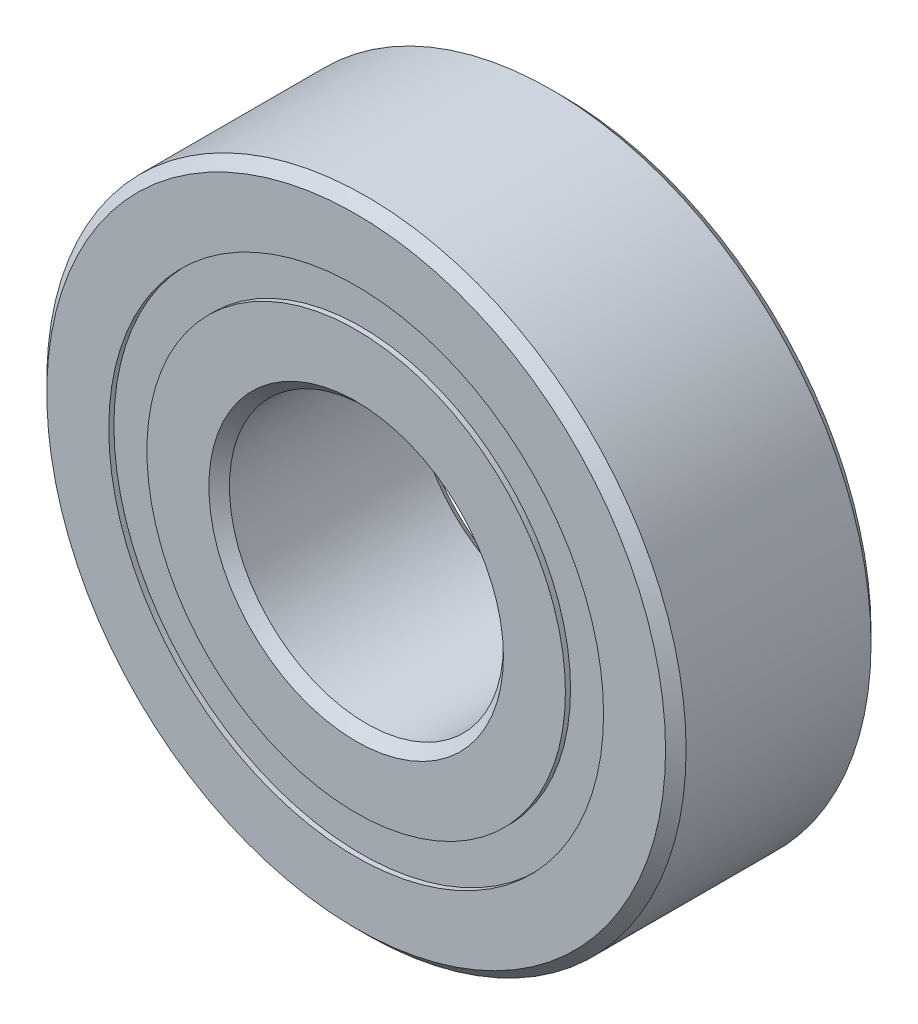
from build123d import *

# Parameters (mm, degrees)
CIRPATTERN1_COUNT = 10
SKETCH5_W         = 1.672929924
SKETCH5_H         = 1.325824176


with BuildPart() as part:
    # Sketch1 → Revolve1 (revolve)
    with BuildSketch(Plane(origin=(0, 0, 0), x_dir=(0, 0, -1), z_dir=(1, 0, 0))):
        with BuildLine():
            Line((3.2146875, 11.1125), (-3.2146875, 11.1125))
            Line((-3.2146875, 11.1125), (-3.571875, 10.7553125))
            Line((-3.571875, 10.7553125), (-3.571875, 8.600412088))
            Line((-3.571875, 8.600412088), (-1.5875, 8.600412088))
            ThreePointArc((-1.5875, 8.600412088), (0, 9.657851326), (1.5875, 8.600412088))
            Line((1.5875, 8.600412088), (3.571875, 8.600412088))
            Line((3.571875, 8.600412088), (3.571875, 10.7553125))
            Line((3.571875, 10.7553125), (3.2146875, 11.1125))
        make_face()
    revolve(axis=Axis((0, 0, 3.571875), (0, 0, -1)))


with BuildPart() as body_2:
    # Sketch3 → Revolve3 (revolve)
    with BuildSketch(Plane(origin=(0, 0, 0), x_dir=(0, 0, -1), z_dir=(1, 0, 0))):
        with BuildLine():
            Line((-3.571875, 7.274587912), (-1.5875, 7.274587912))
            ThreePointArc((-1.5875, 7.274587912), (0, 6.217148674), (1.5875, 7.274587912))
            Line((1.5875, 7.274587912), (3.571875, 7.274587912))
            Line((3.571875, 7.274587912), (3.571875, 5.1196875))
            Line((3.571875, 5.1196875), (3.2146875, 4.7625))
            Line((3.2146875, 4.7625), (-3.2146875, 4.7625))
            Line((-3.2146875, 4.7625), (-3.571875, 5.1196875))
            Line((-3.571875, 5.1196875), (-3.571875, 7.274587912))
        make_face()
    revolve(axis=Axis((0, 0, 3.571875), (0, 0, -1)))


with BuildPart() as body_3:
    # Sketch4 → Revolve4 (revolve)
    with BuildSketch(Plane(origin=(0, 0, 0), x_dir=(0, 0, -1), z_dir=(1, 0, 0))):
        with BuildLine():
            Line((-1.720351326, 7.9375), (1.720351326, 7.9375))
            ThreePointArc((1.720351326, 7.9375), (0, 9.657851326), (-1.720351326, 7.9375))
        make_face()
    revolve(axis=Axis((0, 7.9375, 1.720351326), (0, 0, -1)))


with BuildPart() as cirpattern1_1:
    # CirPattern1: pattern copy
    add(body_3.part.rotate(Axis((0, 0, -3.571875), (0, 0, 1)), 1 * 360 / CIRPATTERN1_COUNT))


with BuildPart() as cirpattern1_2:
    # CirPattern1: pattern copy
    add(body_3.part.rotate(Axis((0, 0, -3.571875), (0, 0, 1)), 2 * 360 / CIRPATTERN1_COUNT))


with BuildPart() as cirpattern1_3:
    # CirPattern1: pattern copy
    add(body_3.part.rotate(Axis((0, 0, -3.571875), (0, 0, 1)), 3 * 360 / CIRPATTERN1_COUNT))


with BuildPart() as cirpattern1_4:
    # CirPattern1: pattern copy
    add(body_3.part.rotate(Axis((0, 0, -3.571875), (0, 0, 1)), 4 * 360 / CIRPATTERN1_COUNT))


with BuildPart() as cirpattern1_5:
    # CirPattern1: pattern copy
    add(body_3.part.rotate(Axis((0, 0, -3.571875), (0, 0, 1)), 5 * 360 / CIRPATTERN1_COUNT))


with BuildPart() as cirpattern1_6:
    # CirPattern1: pattern copy
    add(body_3.part.rotate(Axis((0, 0, -3.571875), (0, 0, 1)), 6 * 360 / CIRPATTERN1_COUNT))


with BuildPart() as cirpattern1_7:
    # CirPattern1: pattern copy
    add(body_3.part.rotate(Axis((0, 0, -3.571875), (0, 0, 1)), 7 * 360 / CIRPATTERN1_COUNT))


with BuildPart() as cirpattern1_8:
    # CirPattern1: pattern copy
    add(body_3.part.rotate(Axis((0, 0, -3.571875), (0, 0, 1)), 8 * 360 / CIRPATTERN1_COUNT))


with BuildPart() as cirpattern1_9:
    # CirPattern1: pattern copy
    add(body_3.part.rotate(Axis((0, 0, -3.571875), (0, 0, 1)), 9 * 360 / CIRPATTERN1_COUNT))


with BuildPart() as body_13:
    # Sketch5 → Revolve5 (revolve)
    with BuildSketch(Plane(origin=(0, 0, 0), x_dir=(0, 0, -1), z_dir=(1, 0, 0))):
        with Locations((-2.556816288, 7.9375)):
            Rectangle(SKETCH5_W, SKETCH5_H)
        with Locations((2.556816288, 7.9375)):
            Rectangle(SKETCH5_W, SKETCH5_H)
    revolve(axis=Axis((0, 0, 3.571875), (0, 0, -1)))


solid = Compound([part.part, body_2.part, body_3.part, cirpattern1_1.part, cirpattern1_2.part, cirpattern1_3.part, cirpattern1_4.part, cirpattern1_5.part, cirpattern1_6.part, cirpattern1_7.part, cirpattern1_8.part, cirpattern1_9.part, body_13.part])
